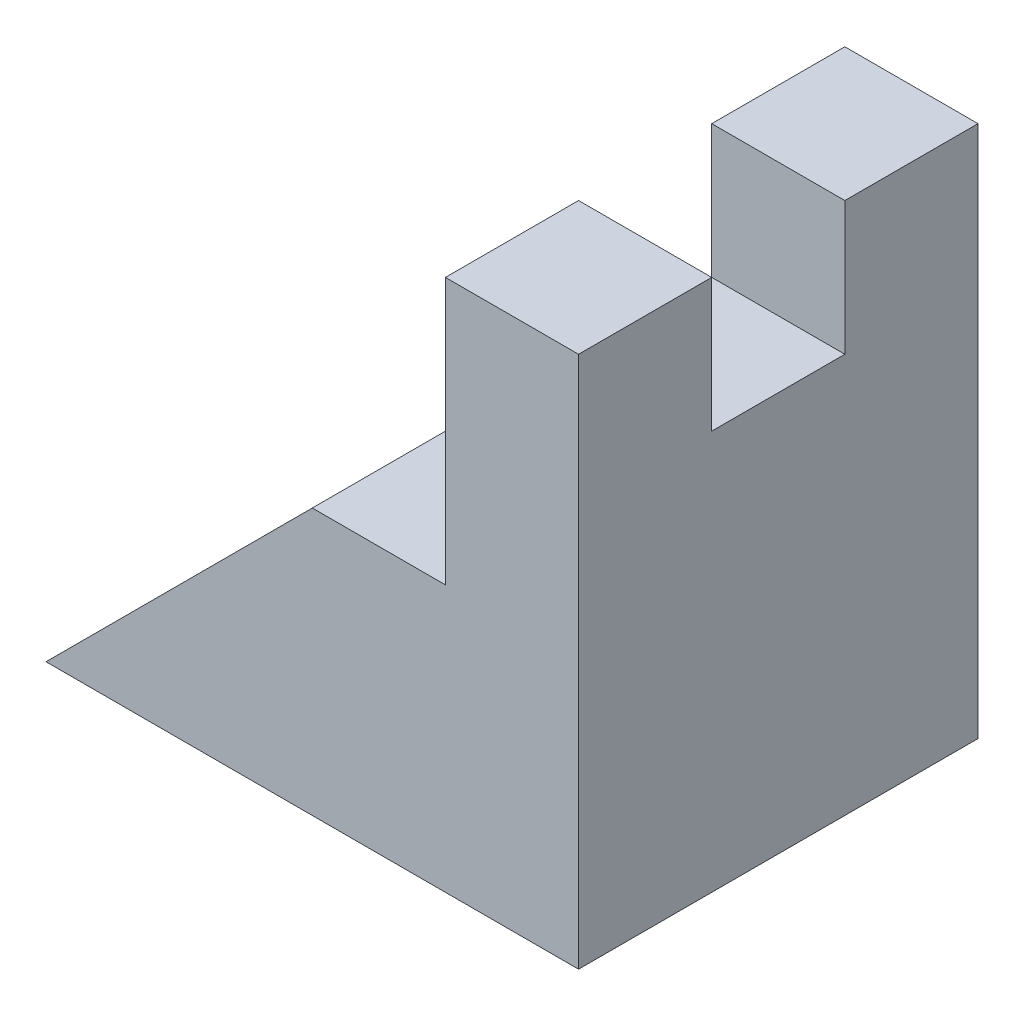
from build123d import *

# Parameters (mm, degrees)
RESSALTO_EXTRUS_O1_DEPTH = 15
ESBO_O2_W                = 10
ESBO_O2_H                = 10
CORTE_EXTRUS_O1_DEPTH    = 41


with BuildPart() as part:
    # Esboço1 → Ressalto-extrusão1 (new body, symmetric)
    with BuildSketch(Plane.XY):
        Polygon((0, 0), (20, 20), (30, 20), (30, 40), (40, 40), (40, 0), align=None)
    extrude(amount=RESSALTO_EXTRUS_O1_DEPTH, both=True)

    # Esboço2 → Corte-extrusão1 (cut, through all)
    with BuildSketch(Plane(origin=(40, 0, 0), x_dir=(0, 0, -1), z_dir=(1, 0, 0))):
        with Locations((0, 35)):
            Rectangle(ESBO_O2_W, ESBO_O2_H)
    extrude(amount=-CORTE_EXTRUS_O1_DEPTH, mode=Mode.SUBTRACT)


solid = part.part
